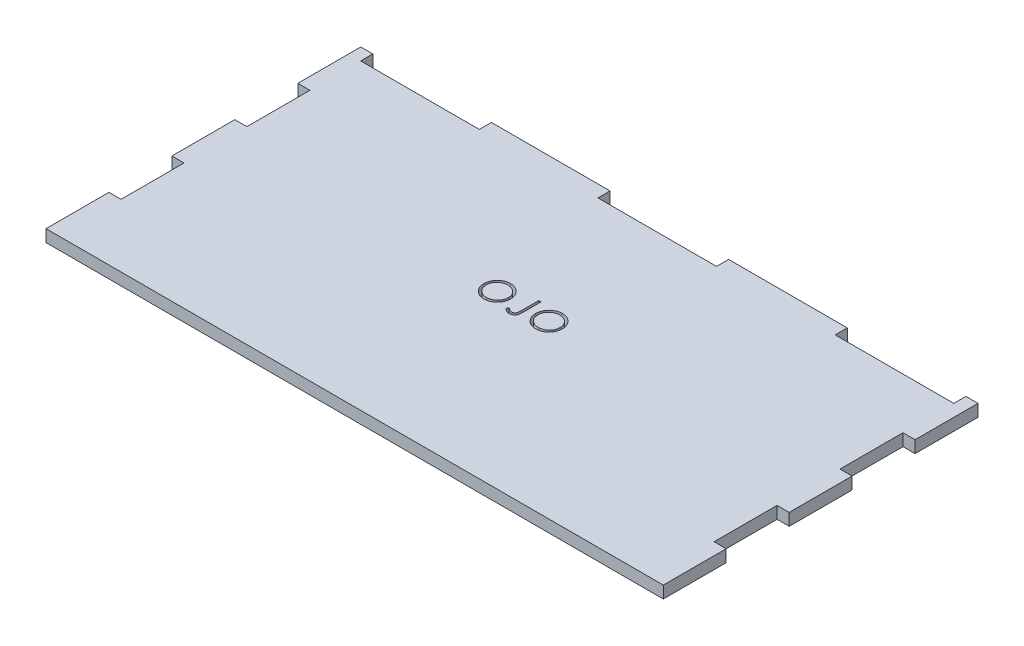
from build123d import *

# Parameters (mm, degrees)
BOSS_EXTRUDE1_DEPTH = 3
CUT_EXTRUDE1_DEPTH  = 4


with BuildPart() as part:
    # Sketch1 → Boss-Extrude1 (new body)
    with BuildSketch(Plane(origin=(0, 0, 0), x_dir=(1, 0, 0), z_dir=(0, 1, 0))):
        Polygon((-73.5, 33), (-44.1, 33), (-44.1, 36), (-14.7, 36), (-14.7, 33), (14.7, 33), (14.7, 36), (44.1, 36), (44.1, 33), (73.5, 33), (73.5, 36), (76.5, 36), (76.5, 20.4), (73.5, 20.4), (73.5, 4.8), (76.5, 4.8), (76.5, -10.8), (73.5, -10.8), (73.5, -26.4), (76.5, -26.4), (76.5, -42), (-76.5, -42), (-76.5, -26.4), (-73.5, -26.4), (-73.5, -10.8), (-76.5, -10.8), (-76.5, 4.8), (-73.5, 4.8), (-73.5, 20.4), (-76.5, 20.4), (-76.5, 36), (-73.5, 36), align=None)
    extrude(amount=BOSS_EXTRUDE1_DEPTH)

    # Sketch2 → Cut-Extrude1 (cut, through all)
    with BuildSketch(Plane(origin=(0, 3, 0), x_dir=(1, 0, 0), z_dir=(0, 1, 0))):
        with BuildLine():
            add(Edge.make_bspline(
                [(-7.176098448, 3.786895233), (-7.059666273, 3.783946203), (-6.830983876, 3.778154066), (-6.494891086, 3.733816377), (-6.174032839, 3.657111202), (-5.865795404, 3.554952983), (-5.573865709, 3.418675415), (-5.296046411, 3.253956804), (-5.032998529, 3.059071461), (-4.788267543, 2.835525884), (-4.564312845, 2.592300292), (-4.367003163, 2.33273589), (-4.201642916, 2.058402096), (-4.065847904, 1.77012329), (-3.959313915, 1.468551429), (-3.885800067, 1.152078771), (-3.838841101, 0.822755822), (-3.833351188, 0.598136548), (-3.830566221, 0.48418985)],
                knots=[0, 0, 0, 0, 0.00034924, 0.000685936, 0.001014683, 0.001337727, 0.001658397, 0.001979193, 0.002305187, 0.002638687, 0.002972106, 0.003295829, 0.003615111, 0.003931216, 0.004250316, 0.004572644, 0.004904516, 0.005246205, 0.005246205, 0.005246205, 0.005246205], degree=3))
            add(Edge.make_bspline(
                [(-3.830566221, 0.48418985), (-3.83335078, 0.371082511), (-3.838839469, 0.148134843), (-3.88585346, -0.179098255), (-3.95958641, -0.493660611), (-4.064858592, -0.795027096), (-4.200006285, -1.083515622), (-4.366467608, -1.3583671), (-4.562547223, -1.619671636), (-4.785693287, -1.86456662), (-5.028950478, -2.089133086), (-5.289866539, -2.284813261), (-5.562573573, -2.453195032), (-5.850580877, -2.587548993), (-6.150068842, -2.694933318), (-6.463717871, -2.768148192), (-6.790058272, -2.815374655), (-7.012600964, -2.820797624), (-7.125713926, -2.823553986)],
                knots=[0, 0, 0, 0, 0.000339173, 0.000668549, 0.000989652, 0.001307147, 0.001624392, 0.001943673, 0.002269409, 0.002602909, 0.002936329, 0.003261057, 0.003579916, 0.003896021, 0.004212746, 0.004532623, 0.004860751, 0.005199924, 0.005199924, 0.005199924, 0.005199924], degree=3))
            add(Edge.make_bspline(
                [(-7.125713926, -2.823553986), (-7.239660033, -2.820770407), (-7.464278142, -2.815283232), (-7.794014921, -2.768246556), (-8.110709889, -2.694692716), (-8.413457393, -2.58957653), (-8.70242626, -2.453725027), (-8.978181643, -2.288073583), (-9.239616698, -2.091516206), (-9.484563928, -1.868442501), (-9.708684355, -1.625597605), (-9.904077978, -1.365393006), (-10.069766673, -1.092933653), (-10.205162031, -0.807463433), (-10.312353294, -0.510362378), (-10.385482271, -0.199648664), (-10.432796602, 0.122906282), (-10.43824891, 0.342523971), (-10.44101544, 0.453959137)],
                knots=[0, 0, 0, 0, 0.00034169, 0.000673561, 0.000997115, 0.0013158, 0.001633045, 0.001953405, 0.002279141, 0.002612641, 0.002946061, 0.003269026, 0.003587229, 0.003901058, 0.004215409, 0.004532836, 0.004857223, 0.005191362, 0.005191362, 0.005191362, 0.005191362], degree=3))
            add(Edge.make_bspline(
                [(-10.44101544, 0.453959137), (-10.440054931, 0.528755061), (-10.43814603, 0.677403326), (-10.415164883, 0.898141538), (-10.381817523, 1.115329835), (-10.334025376, 1.328350615), (-10.271519778, 1.536682419), (-10.197767016, 1.741762036), (-10.10768737, 1.941511165), (-10.005856727, 2.136876072), (-9.892202582, 2.324811296), (-9.766666041, 2.502455199), (-9.633656461, 2.671298458), (-9.487840899, 2.826965699), (-9.334025127, 2.973985434), (-9.169713924, 3.110098313), (-8.995909895, 3.236531704), (-8.811865186, 3.350470664), (-8.622114765, 3.453520255), (-8.426510221, 3.541950661), (-8.227708157, 3.617848587), (-8.024777442, 3.67936456), (-7.818256961, 3.727929453), (-7.607695975, 3.760999517), (-7.393262233, 3.784039278), (-7.248797824, 3.785939152), (-7.176098448, 3.786895233)],
                knots=[0, 0, 0, 0, 0.0002243, 0.000445769, 0.000665076, 0.000883266, 0.001100073, 0.001317242, 0.001536581, 0.001756873, 0.001977866, 0.002194878, 0.002409105, 0.002622128, 0.002834178, 0.003047063, 0.003261731, 0.003478432, 0.003695977, 0.003909056, 0.004121942, 0.004333924, 0.004544746, 0.004757833, 0.004973036, 0.00519104, 0.00519104, 0.00519104, 0.00519104], degree=3))
        make_face()
        with BuildLine():
            add(Edge.make_bspline(
                [(-7.148386961, 3.141973358), (-7.208059311, 3.141245945), (-7.32683354, 3.139798073), (-7.503408401, 3.120726218), (-7.677661013, 3.093544342), (-7.849627364, 3.054771671), (-8.018587926, 3.001945288), (-8.186117614, 2.941147793), (-8.350688736, 2.867091297), (-8.511757996, 2.783420263), (-8.667906845, 2.690809117), (-8.815248247, 2.588455459), (-8.954163641, 2.478759609), (-9.084312902, 2.361465565), (-9.205313868, 2.235976), (-9.319548113, 2.104193354), (-9.422436815, 1.962350907), (-9.516730727, 1.814295001), (-9.60111165, 1.660218481), (-9.676145953, 1.501743458), (-9.737523921, 1.337577223), (-9.787580576, 1.16950081), (-9.829080959, 0.997780414), (-9.8553718, 0.821113367), (-9.874653215, 0.640387399), (-9.876018329, 0.51825337), (-9.876708799, 0.456478363)],
                knots=[0, 0, 0, 0, 0.000178936, 0.000356161, 0.000532183, 0.000707884, 0.000884397, 0.001062933, 0.001242241, 0.00142534, 0.001607231, 0.001786477, 0.001963133, 0.002137934, 0.002311637, 0.002485833, 0.002660679, 0.002836795, 0.003012117, 0.003187366, 0.003362362, 0.003537303, 0.003713289, 0.003891798, 0.004072784, 0.004258016, 0.004258016, 0.004258016, 0.004258016], degree=3))
            add(Edge.make_bspline(
                [(-9.876708799, 0.456478363), (-9.874418423, 0.365639891), (-9.869912544, 0.186932515), (-9.830464274, -0.07494988), (-9.769700795, -0.326628023), (-9.680128642, -0.566724812), (-9.568111518, -0.797304054), (-9.429727465, -1.016320263), (-9.265774305, -1.223832634), (-9.079535722, -1.418392457), (-8.875943765, -1.595975674), (-8.659757823, -1.751852045), (-8.433293935, -1.883738556), (-8.195961538, -1.99118244), (-7.949027677, -2.07632133), (-7.690901175, -2.134671402), (-7.423301533, -2.173073863), (-7.240894799, -2.176761779), (-7.148386961, -2.178632111)],
                knots=[0, 0, 0, 0, 0.000272368, 0.000535832, 0.000792759, 0.001047811, 0.001303003, 0.001560563, 0.001823387, 0.002095117, 0.002367417, 0.002632745, 0.002893509, 0.003152248, 0.003413158, 0.003675624, 0.003945149, 0.004222495, 0.004222495, 0.004222495, 0.004222495], degree=3))
            add(Edge.make_bspline(
                [(-7.148386961, -2.178632111), (-7.086208635, -2.177777835), (-6.96289034, -2.176083549), (-6.779468783, -2.159018529), (-6.599351673, -2.131653439), (-6.422791646, -2.092253523), (-6.249989084, -2.042942748), (-6.080222737, -1.984360745), (-5.915300859, -1.911274193), (-5.753142915, -1.830522138), (-5.597926185, -1.738465706), (-5.449753276, -1.639585924), (-5.312358972, -1.530051646), (-5.182307077, -1.414500317), (-5.06080933, -1.290602069), (-4.948687341, -1.158517985), (-4.846318654, -1.017414347), (-4.752060548, -0.869583014), (-4.6679753, -0.715084891), (-4.594712872, -0.556035298), (-4.532558595, -0.392825874), (-4.482383135, -0.225221214), (-4.443064413, -0.053539644), (-4.41597231, 0.122448713), (-4.397021322, 0.30239179), (-4.395592911, 0.42409824), (-4.394872862, 0.485449463)],
                knots=[0, 0, 0, 0, 0.000186491, 0.000369867, 0.000552111, 0.000732728, 0.000912151, 0.001091021, 0.001270974, 0.001452926, 0.001634174, 0.001811998, 0.001986885, 0.002160844, 0.002333645, 0.002507024, 0.00268011, 0.002856226, 0.003032653, 0.003207372, 0.003381189, 0.00355613, 0.003731832, 0.003909097, 0.004090083, 0.004274056, 0.004274056, 0.004274056, 0.004274056], degree=3))
            add(Edge.make_bspline(
                [(-4.394872862, 0.485449463), (-4.395593488, 0.546380975), (-4.397022984, 0.667249854), (-4.415963258, 0.845937985), (-4.443093035, 1.020660001), (-4.482191222, 1.190729968), (-4.532585233, 1.356191238), (-4.594723727, 1.51688841), (-4.667997294, 1.673420144), (-4.752091456, 1.825399558), (-4.846619365, 1.971235501), (-4.949911687, 2.110653518), (-5.063751849, 2.241035389), (-5.184887293, 2.365599887), (-5.31634377, 2.481690325), (-5.457525804, 2.589345213), (-5.606719425, 2.691162608), (-5.764686689, 2.783013161), (-5.92771438, 2.867836744), (-6.094999945, 2.940509725), (-6.264648251, 3.002261578), (-6.436227891, 3.054931502), (-6.611183041, 3.093392485), (-6.788331533, 3.120750714), (-6.967428276, 3.139791435), (-7.087875985, 3.141243742), (-7.148386961, 3.141973358)],
                knots=[0, 0, 0, 0, 0.000182713, 0.000362446, 0.000538467, 0.000712941, 0.000885471, 0.001056936, 0.001229369, 0.001403588, 0.001577583, 0.001750403, 0.001923644, 0.002096446, 0.002271346, 0.002449215, 0.002628788, 0.002812847, 0.002997065, 0.00317983, 0.003359549, 0.003538472, 0.00371786, 0.00389637, 0.004076102, 0.004257556, 0.004257556, 0.004257556, 0.004257556], degree=3))
        make_face(mode=Mode.SUBTRACT)
        with BuildLine():
            Line((0.006718935, 3.625664764), (0.571025576, 3.625664764))
            Line((0.571025576, 3.625664764), (0.571025576, -0.620490784))
            add(Edge.make_bspline(
                [(0.571025576, -0.620490784), (0.5704616, -0.699010099), (0.569378697, -0.849776765), (0.563424132, -1.066934948), (0.552404922, -1.2652234), (0.536352564, -1.445093006), (0.514937054, -1.605980268), (0.490430018, -1.74912833), (0.460763651, -1.873342476), (0.416089351, -2.012819678), (0.342836177, -2.16578632), (0.232586115, -2.330990008), (0.095628706, -2.475494107), (-0.063010112, -2.600989282), (-0.244716847, -2.700981287), (-0.445749616, -2.772763486), (-0.664870894, -2.816547389), (-0.816859138, -2.821171584), (-0.895163999, -2.823553986)],
                knots=[0, 0, 0, 0, 0.000235561, 0.000452306, 0.000651648, 0.000831261, 0.000993907, 0.001138455, 0.001266769, 0.00137671, 0.001577301, 0.001773291, 0.00197023, 0.002172071, 0.002377855, 0.002589429, 0.002810275, 0.003044972, 0.003044972, 0.003044972, 0.003044972], degree=3))
            add(Edge.make_bspline(
                [(-0.895163999, -2.823553986), (-0.956172502, -2.821612598), (-1.07892565, -2.817706397), (-1.261619931, -2.785868133), (-1.443795484, -2.736793001), (-1.626419232, -2.664925615), (-1.813099259, -2.567182254), (-2.006363896, -2.439293885), (-2.208699126, -2.281498568), (-2.34197445, -2.161060694), (-2.411738096, -2.098016876)],
                knots=[0, 0, 0, 0, 0.000182922, 0.000368051, 0.000554754, 0.000748198, 0.000955526, 0.001185759, 0.001442504, 0.001724523, 0.001724523, 0.001724523, 0.001724523], degree=3))
            Line((-2.411738096, -2.098016876), (-2.079200254, -1.61432547))
            add(Edge.make_bspline(
                [(-2.079200254, -1.61432547), (-2.002481984, -1.667229722), (-1.857627887, -1.767119848), (-1.644726591, -1.895622256), (-1.456092057, -2.005797091), (-1.332698466, -2.061943938), (-1.275567136, -2.087939972)],
                knots=[0, 0, 0, 0, 0.000279487, 0.000527707, 0.000745973, 0.000934162, 0.000934162, 0.000934162, 0.000934162], degree=3))
            add(Edge.make_bspline(
                [(-1.275567136, -2.087939972), (-1.240921558, -2.101521052), (-1.172973863, -2.128156574), (-1.069087171, -2.157882406), (-0.965793423, -2.174127711), (-0.897312391, -2.177148341), (-0.863673673, -2.178632111)],
                knots=[0, 0, 0, 0, 0.000111602, 0.000218876, 0.000323455, 0.00042442, 0.00042442, 0.00042442, 0.00042442], degree=3))
            add(Edge.make_bspline(
                [(-0.863673673, -2.178632111), (-0.820227648, -2.176794698), (-0.734350874, -2.17316281), (-0.609554079, -2.141095372), (-0.490157702, -2.092148947), (-0.380441904, -2.020481522), (-0.279321374, -1.935267745), (-0.195883676, -1.832223771), (-0.126325511, -1.718023153), (-0.084466025, -1.60992104), (-0.057796382, -1.511331438), (-0.040869788, -1.420724875), (-0.026068473, -1.314796565), (-0.013166326, -1.193420066), (-0.005612709, -1.056352374), (0.002862193, -0.903995957), (0.00592581, -0.735966696), (0.006446493, -0.618810781), (0.006718935, -0.557510132)],
                knots=[0, 0, 0, 0, 0.000130131, 0.000257221, 0.000384248, 0.000515635, 0.000648708, 0.000779344, 0.000911549, 0.001048384, 0.001125385, 0.001217776, 0.001324658, 0.001446235, 0.001583815, 0.001736416, 0.001903987, 0.002087895, 0.002087895, 0.002087895, 0.002087895], degree=3))
            Line((0.006718935, -0.557510132), (0.006718935, 3.625664764))
        make_face()
        with BuildLine():
            add(Edge.make_bspline(
                [(5.657846865, 3.786895233), (5.774279039, 3.783946203), (6.002961436, 3.778154066), (6.339054226, 3.733816377), (6.659912474, 3.657111202), (6.968149908, 3.554952983), (7.260079603, 3.418675415), (7.537898902, 3.253956804), (7.800946784, 3.059071461), (8.04567777, 2.835525884), (8.269632467, 2.592300292), (8.466942149, 2.33273589), (8.632302396, 2.058402096), (8.768097409, 1.77012329), (8.874631398, 1.468551429), (8.948145246, 1.152078771), (8.995104212, 0.822755822), (9.000594124, 0.598136548), (9.003379092, 0.48418985)],
                knots=[0, 0, 0, 0, 0.00034924, 0.000685936, 0.001014683, 0.001337727, 0.001658397, 0.001979193, 0.002305187, 0.002638687, 0.002972106, 0.003295829, 0.003615111, 0.003931216, 0.004250316, 0.004572644, 0.004904516, 0.005246205, 0.005246205, 0.005246205, 0.005246205], degree=3))
            add(Edge.make_bspline(
                [(9.003379092, 0.48418985), (9.000594532, 0.371082511), (8.995105843, 0.148134843), (8.948091853, -0.179098255), (8.874358902, -0.493660611), (8.769086721, -0.795027096), (8.633939027, -1.083515622), (8.467477704, -1.3583671), (8.271398089, -1.619671636), (8.048252025, -1.86456662), (7.804994835, -2.089133086), (7.544078773, -2.284813261), (7.27137174, -2.453195032), (6.983364435, -2.587548993), (6.68387647, -2.694933318), (6.370227441, -2.768148192), (6.04388704, -2.815374655), (5.821344349, -2.820797624), (5.708231386, -2.823553986)],
                knots=[0, 0, 0, 0, 0.000339173, 0.000668549, 0.000989652, 0.001307147, 0.001624392, 0.001943673, 0.002269409, 0.002602909, 0.002936329, 0.003261057, 0.003579916, 0.003896021, 0.004212746, 0.004532623, 0.004860751, 0.005199924, 0.005199924, 0.005199924, 0.005199924], degree=3))
            add(Edge.make_bspline(
                [(5.708231386, -2.823553986), (5.594285279, -2.820770407), (5.369667171, -2.815283232), (5.039930391, -2.768246556), (4.723235424, -2.694692716), (4.420487919, -2.58957653), (4.131519053, -2.453725027), (3.855763669, -2.288073583), (3.594328614, -2.091516206), (3.349381385, -1.868442501), (3.125260957, -1.625597605), (2.929867334, -1.365393006), (2.76417864, -1.092933653), (2.628783282, -0.807463433), (2.521592019, -0.510362378), (2.448463042, -0.199648664), (2.401148711, 0.122906282), (2.395696403, 0.342523971), (2.392929873, 0.453959137)],
                knots=[0, 0, 0, 0, 0.00034169, 0.000673561, 0.000997115, 0.0013158, 0.001633045, 0.001953405, 0.002279141, 0.002612641, 0.002946061, 0.003269026, 0.003587229, 0.003901058, 0.004215409, 0.004532836, 0.004857223, 0.005191362, 0.005191362, 0.005191362, 0.005191362], degree=3))
            add(Edge.make_bspline(
                [(2.392929873, 0.453959137), (2.393890382, 0.528755061), (2.395799283, 0.677403326), (2.418780429, 0.898141538), (2.452127789, 1.115329835), (2.499919936, 1.328350615), (2.562425534, 1.536682419), (2.636178296, 1.741762036), (2.726257942, 1.941511165), (2.828088585, 2.136876072), (2.94174273, 2.324811296), (3.067279271, 2.502455199), (3.200288851, 2.671298458), (3.346104413, 2.826965699), (3.499920186, 2.973985434), (3.664231389, 3.110098313), (3.838035417, 3.236531704), (4.022080127, 3.350470664), (4.211830548, 3.453520255), (4.407435092, 3.541950661), (4.606237156, 3.617848587), (4.809167871, 3.67936456), (5.015688352, 3.727929453), (5.226249337, 3.760999517), (5.440683079, 3.784039278), (5.585147488, 3.785939152), (5.657846865, 3.786895233)],
                knots=[0, 0, 0, 0, 0.0002243, 0.000445769, 0.000665076, 0.000883266, 0.001100073, 0.001317242, 0.001536581, 0.001756873, 0.001977866, 0.002194878, 0.002409105, 0.002622128, 0.002834178, 0.003047063, 0.003261731, 0.003478432, 0.003695977, 0.003909056, 0.004121942, 0.004333924, 0.004544746, 0.004757833, 0.004973036, 0.00519104, 0.00519104, 0.00519104, 0.00519104], degree=3))
        make_face()
        with BuildLine():
            add(Edge.make_bspline(
                [(5.685558352, 3.141973358), (5.625886001, 3.141245945), (5.507111772, 3.139798073), (5.330536912, 3.120726218), (5.156284299, 3.093544342), (4.984317949, 3.054771671), (4.815357387, 3.001945288), (4.647827699, 2.941147793), (4.483256576, 2.867091297), (4.322187317, 2.783420263), (4.166038467, 2.690809117), (4.018697066, 2.588455459), (3.879781671, 2.478759609), (3.749632411, 2.361465565), (3.628631445, 2.235976), (3.5143972, 2.104193354), (3.411508497, 1.962350907), (3.317214585, 1.814295001), (3.232833663, 1.660218481), (3.15779936, 1.501743458), (3.096421392, 1.337577223), (3.046364736, 1.16950081), (3.004864353, 0.997780414), (2.978573512, 0.821113367), (2.959292098, 0.640387399), (2.957926984, 0.51825337), (2.957236513, 0.456478363)],
                knots=[0, 0, 0, 0, 0.000178936, 0.000356161, 0.000532183, 0.000707884, 0.000884397, 0.001062933, 0.001242241, 0.00142534, 0.001607231, 0.001786477, 0.001963133, 0.002137934, 0.002311637, 0.002485833, 0.002660679, 0.002836795, 0.003012117, 0.003187366, 0.003362362, 0.003537303, 0.003713289, 0.003891798, 0.004072784, 0.004258016, 0.004258016, 0.004258016, 0.004258016], degree=3))
            add(Edge.make_bspline(
                [(2.957236513, 0.456478363), (2.95952689, 0.365639891), (2.964032768, 0.186932515), (3.003481038, -0.07494988), (3.064244518, -0.326628023), (3.153816671, -0.566724812), (3.265833795, -0.797304054), (3.404217847, -1.016320263), (3.568171008, -1.223832634), (3.754409591, -1.418392457), (3.958001548, -1.595975674), (4.17418749, -1.751852045), (4.400651377, -1.883738556), (4.637983775, -1.99118244), (4.884917636, -2.07632133), (5.143044138, -2.134671402), (5.410643779, -2.173073863), (5.593050513, -2.176761779), (5.685558352, -2.178632111)],
                knots=[0, 0, 0, 0, 0.000272368, 0.000535832, 0.000792759, 0.001047811, 0.001303003, 0.001560563, 0.001823387, 0.002095117, 0.002367417, 0.002632745, 0.002893509, 0.003152248, 0.003413158, 0.003675624, 0.003945149, 0.004222495, 0.004222495, 0.004222495, 0.004222495], degree=3))
            add(Edge.make_bspline(
                [(5.685558352, -2.178632111), (5.747736678, -2.177777835), (5.871054973, -2.176083549), (6.054476529, -2.159018529), (6.234593639, -2.131653439), (6.411153667, -2.092253523), (6.583956229, -2.042942748), (6.753722576, -1.984360745), (6.918644454, -1.911274193), (7.080802397, -1.830522138), (7.236019127, -1.738465706), (7.384192036, -1.639585924), (7.52158634, -1.530051646), (7.651638236, -1.414500317), (7.773135983, -1.290602069), (7.885257972, -1.158517985), (7.987626659, -1.017414347), (8.081884765, -0.869583014), (8.165970012, -0.715084891), (8.23923244, -0.556035298), (8.301386718, -0.392825874), (8.351562178, -0.225221214), (8.3908809, -0.053539644), (8.417973003, 0.122448713), (8.436923991, 0.30239179), (8.438352401, 0.42409824), (8.439072451, 0.485449463)],
                knots=[0, 0, 0, 0, 0.000186491, 0.000369867, 0.000552111, 0.000732728, 0.000912151, 0.001091021, 0.001270974, 0.001452926, 0.001634174, 0.001811998, 0.001986885, 0.002160844, 0.002333645, 0.002507024, 0.00268011, 0.002856226, 0.003032653, 0.003207372, 0.003381189, 0.00355613, 0.003731832, 0.003909097, 0.004090083, 0.004274056, 0.004274056, 0.004274056, 0.004274056], degree=3))
            add(Edge.make_bspline(
                [(8.439072451, 0.485449463), (8.438351824, 0.546380975), (8.436922328, 0.667249854), (8.417982055, 0.845937985), (8.390852277, 1.020660001), (8.351754091, 1.190729968), (8.30136008, 1.356191238), (8.239221586, 1.51688841), (8.165948019, 1.673420144), (8.081853857, 1.825399558), (7.987325948, 1.971235501), (7.884033626, 2.110653518), (7.770193464, 2.241035389), (7.64905802, 2.365599887), (7.517601543, 2.481690325), (7.376419508, 2.589345213), (7.227225888, 2.691162608), (7.069258623, 2.783013161), (6.906230932, 2.867836744), (6.738945368, 2.940509725), (6.569297061, 3.002261578), (6.397717422, 3.054931502), (6.222762271, 3.093392485), (6.04561378, 3.120750714), (5.866517036, 3.139791435), (5.746069328, 3.141243742), (5.685558352, 3.141973358)],
                knots=[0, 0, 0, 0, 0.000182713, 0.000362446, 0.000538467, 0.000712941, 0.000885471, 0.001056936, 0.001229369, 0.001403588, 0.001577583, 0.001750403, 0.001923644, 0.002096446, 0.002271346, 0.002449215, 0.002628788, 0.002812847, 0.002997065, 0.00317983, 0.003359549, 0.003538472, 0.00371786, 0.00389637, 0.004076102, 0.004257556, 0.004257556, 0.004257556, 0.004257556], degree=3))
        make_face(mode=Mode.SUBTRACT)
    extrude(amount=-CUT_EXTRUDE1_DEPTH, mode=Mode.SUBTRACT)


solid = part.part
